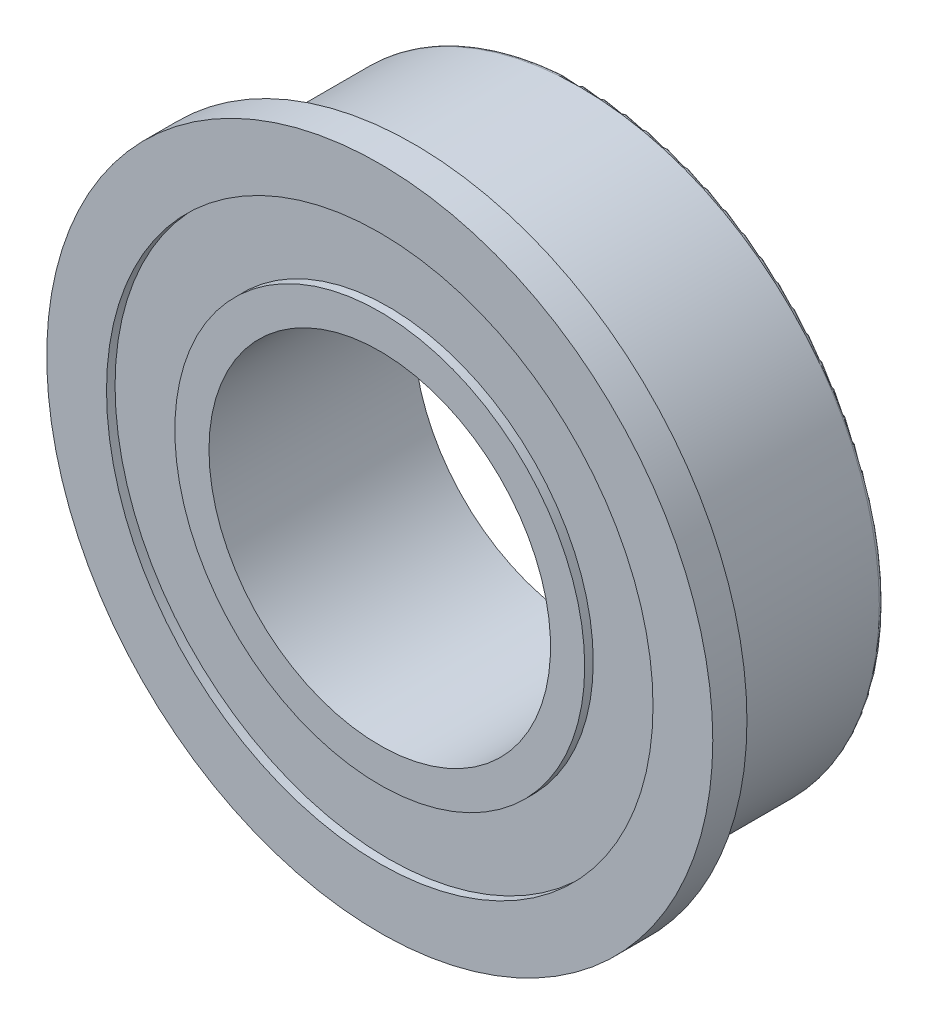
from build123d import *

# Parameters (mm, degrees)
SKETCH_1_R          = 7
EXTRUDE_1_DEPTH     = 4.8
SKETCH_2_R          = 7.8
EXTRUDE_2_DEPTH     = 0.8
SKETCH_3_R          = 4
CUT_EXTRUDE_1_DEPTH = 5.8
SKETCH_4_R          = 6.2
SKETCH_4_R_2        = 4.8
CUT_EXTRUDE_2_DEPTH = 0.2
SKETCH_5_R          = 6.4
SKETCH_5_R_2        = 4.8
CUT_EXTRUDE_3_DEPTH = 0.2
FILLET_1_R          = 0.1


with BuildPart() as part:
    # 草圖1 → 填料-伸長1 (new body)
    with BuildSketch(Plane.XY):
        Circle(SKETCH_1_R)
    extrude(amount=EXTRUDE_1_DEPTH)

    # 草圖2 → 填料-伸長2 (add)
    with BuildSketch(Plane.XY.offset(4.8)):
        Circle(SKETCH_2_R)
    extrude(amount=-EXTRUDE_2_DEPTH)

    # 草圖3 → 除料-伸長1 (cut, through all)
    with BuildSketch(Plane(origin=(0, 0, 0), x_dir=(-1, 0, 0), z_dir=(0, 0, -1))):
        Circle(SKETCH_3_R)
    extrude(amount=-CUT_EXTRUDE_1_DEPTH, mode=Mode.SUBTRACT)

    # 草圖4 → 除料-伸長2 (cut)
    with BuildSketch(Plane(origin=(0, 0, 0), x_dir=(-1, 0, 0), z_dir=(0, 0, -1))):
        Circle(SKETCH_4_R)
        Circle(SKETCH_4_R_2, mode=Mode.SUBTRACT)
    extrude(amount=-CUT_EXTRUDE_2_DEPTH, mode=Mode.SUBTRACT)

    # 草圖5 → 除料-伸長3 (cut)
    with BuildSketch(Plane.XY.offset(4.8)):
        Circle(SKETCH_5_R)
        Circle(SKETCH_5_R_2, mode=Mode.SUBTRACT)
    extrude(amount=-CUT_EXTRUDE_3_DEPTH, mode=Mode.SUBTRACT)

    # 圓角1
    fillet_1_edges = [part.edges().sort_by_distance(p)[0] for p in [
        (-7, 0, 0),
    ]]
    fillet(fillet_1_edges, radius=FILLET_1_R)


solid = part.part
